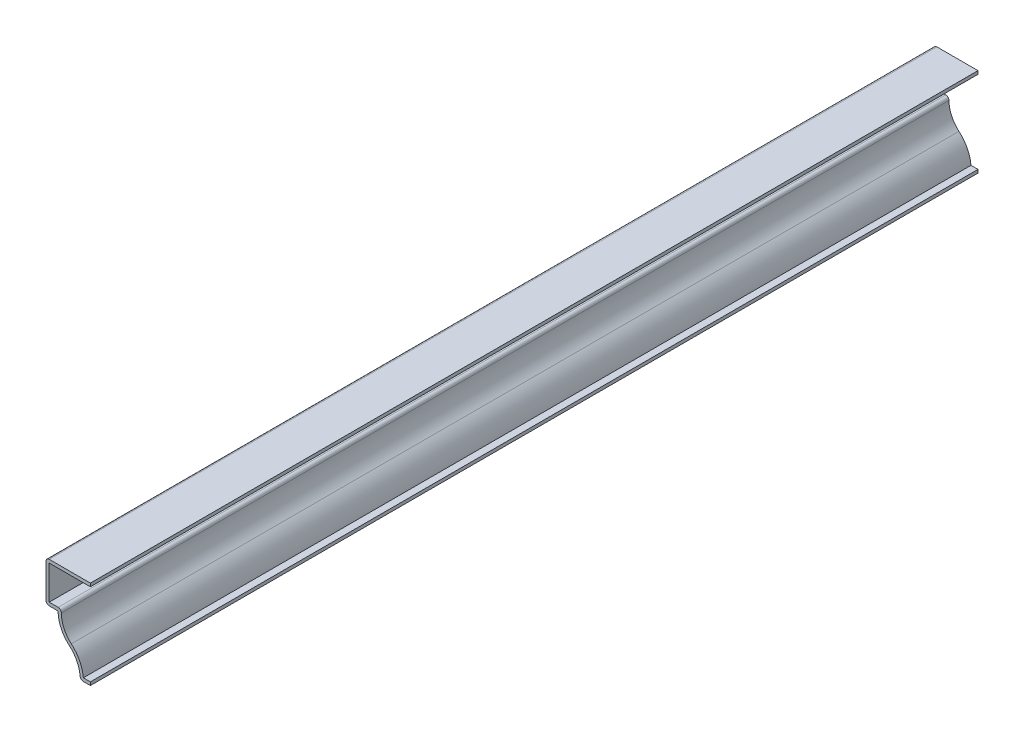
from build123d import *

# Parameters (mm, degrees)
EXTRUDE_THIN1_DEPTH = 349.25
FILLET1_R           = 1.27


with BuildPart() as part:
    # Sketch1 → Extrude-Thin1 (new body)
    with BuildSketch(Plane.XY):
        with BuildLine():
            Line((0, 34.925), (-17.4625, 34.925))
            Line((-17.4625, 34.925), (-17.4625, 19.05))
            Line((-17.4625, 19.05), (-12.7, 19.05))
            ThreePointArc((-12.7, 19.05), (-11.5566064, 13.811099671), (-8.334375, 9.525))
            ThreePointArc((-8.334375, 9.525), (-5.1121436, 5.238900329), (-3.96875, 0))
            Line((-3.96875, 0), (0, 0))
            Line((0, 0), (0, 1.27))
            Line((0, 1.27), (-2.757126928, 1.27))
            ThreePointArc((-2.757126928, 1.27), (-4.23576048, 6.339833525), (-7.505321915, 10.487065997))
            ThreePointArc((-7.505321915, 10.487065997), (-10.650811196, 14.925884165), (-11.358429664, 20.32))
            Line((-11.358429664, 20.32), (-16.1925, 20.32))
            Line((-16.1925, 20.32), (-16.1925, 33.655))
            Line((-16.1925, 33.655), (0, 33.655))
            Line((0, 33.655), (0, 34.925))
        make_face()
    extrude(amount=-EXTRUDE_THIN1_DEPTH)

    # Fillet1
    fillet1_edges = [part.edges().sort_by_distance(p)[0] for p in [
        (-3.96875, 0, -174.625),
        (-17.4625, 19.05, -174.625),
        (-17.4625, 34.925, -174.625),
        (-11.358429664, 20.32, -174.625),
    ]]
    fillet(fillet1_edges, radius=FILLET1_R)


solid = part.part
